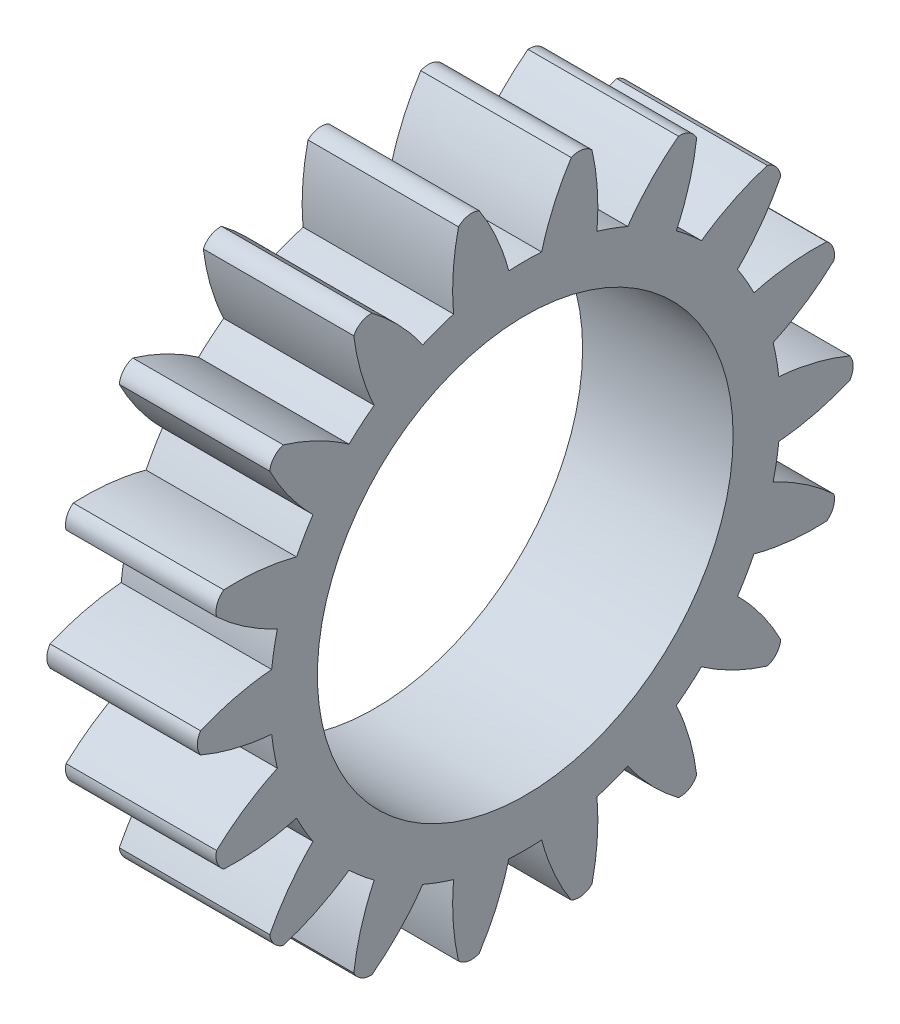
from build123d import *

# Parameters (mm, degrees)
BASPROSKE_W                          = 8
BASPROSKE_H                          = 17.5
TOOTHCUT_DEPTH                       = 27.009613607
TEETHCUTS_COUNT                      = 18
TEETHCUTS_ANGLE                      = 340
BORSKE_R                             = 4
BORE_DEPTH                           = 50.0000508
ESQUISSE1_R                          = 11.05
ENL_V_MAT_EXTRU_1_DEPTH              = 10
ENL_V_MAT_EXTRU_2_DEPTH              = 10
R_P_TITION_CIRCULAIRE1_COUNT         = 18
R_P_TITION_CIRCULAIRE1_COPY_1_DEPTH  = 10
R_P_TITION_CIRCULAIRE1_COPY_2_DEPTH  = 10
R_P_TITION_CIRCULAIRE1_COPY_3_DEPTH  = 10
R_P_TITION_CIRCULAIRE1_COPY_4_DEPTH  = 10
R_P_TITION_CIRCULAIRE1_COPY_5_DEPTH  = 10
R_P_TITION_CIRCULAIRE1_COPY_6_DEPTH  = 10
R_P_TITION_CIRCULAIRE1_COPY_7_DEPTH  = 10
R_P_TITION_CIRCULAIRE1_COPY_8_DEPTH  = 10
R_P_TITION_CIRCULAIRE1_COPY_9_DEPTH  = 10
R_P_TITION_CIRCULAIRE1_COPY_10_DEPTH = 10
R_P_TITION_CIRCULAIRE1_COPY_11_DEPTH = 10
R_P_TITION_CIRCULAIRE1_COPY_12_DEPTH = 10
R_P_TITION_CIRCULAIRE1_COPY_13_DEPTH = 10
R_P_TITION_CIRCULAIRE1_COPY_14_DEPTH = 10
R_P_TITION_CIRCULAIRE1_COPY_15_DEPTH = 10
R_P_TITION_CIRCULAIRE1_COPY_16_DEPTH = 10
R_P_TITION_CIRCULAIRE1_COPY_17_DEPTH = 10


with BuildPart() as part:
    # BasProSke → Base-Revolve (revolve)
    with BuildSketch(Plane(origin=(0, 0, 0), x_dir=(1, 0, 0), z_dir=(0, 1, 0)), mode=Mode.PRIVATE) as base_revolve_sk:
        with Locations((4, 8.75)):
            Rectangle(BASPROSKE_W, BASPROSKE_H)
    revolve(base_revolve_sk.sketch.rotate(Axis((-10, 0, 0), (1, 0, 0)), 180), axis=Axis((-10, 0, 0), (1, 0, 0)))

    # TooCutSke → ToothCut (cut, through all)
    with BuildSketch(Plane(origin=(0, 0, 0), x_dir=(0, 0, -1), z_dir=(1, 0, 0))):
        with BuildLine():
            ThreePointArc((0.873326889, 13.533350745), (0, 13.5615), (-0.873326889, 13.533350745))
            ThreePointArc((-0.873326889, 13.533350745), (-1.417662776, 15.579682129), (-2.609262071, 17.330072031))
            ThreePointArc((-2.609262071, 17.330072031), (0, 17.5254), (2.609262071, 17.330072031))
            ThreePointArc((2.609262071, 17.330072031), (1.417662776, 15.579682129), (0.873326889, 13.533350745))
        make_face()
    toothcut = extrude(amount=TOOTHCUT_DEPTH, mode=Mode.SUBTRACT)

    # TeethCuts: ToothCut ×18 about axis
    teethcuts_axis = Axis((-10, 0, 0), (1, 0, 0))
    for i in range(1, TEETHCUTS_COUNT):
        add(toothcut.rotate(teethcuts_axis, i * TEETHCUTS_ANGLE / (TEETHCUTS_COUNT - 1)), mode=Mode.SUBTRACT)

    # BorSke → Bore (cut, symmetric)
    with BuildSketch(Plane(origin=(0, 0, 0), x_dir=(0, 0, -1), z_dir=(1, 0, 0))):
        with Locations(Location((0, 0, 0), (0, 0, 180))):
            Circle(BORSKE_R)
    extrude(amount=BORE_DEPTH, both=True, mode=Mode.SUBTRACT)

    # Esquisse1 → Enlèv. mat.-Extru.1 (cut)
    with BuildSketch(Plane(origin=(8, 0, 0), x_dir=(0, 0, -1), z_dir=(1, 0, 0))):
        Circle(ESQUISSE1_R)
    extrude(amount=-ENL_V_MAT_EXTRU_1_DEPTH, mode=Mode.SUBTRACT)

    # Esquisse3 → Enlèv. mat.-Extru.2 (cut)
    with BuildSketch(Plane(origin=(8, 0, 0), x_dir=(0, 0, -1), z_dir=(1, 0, 0))):
        with BuildLine():
            add(Edge.make_bspline(
                [(13.479400361, 1.489982603), (15.446382993, 1.323934244), (17.259242087, 0.558889578)],
                knots=[0.341918243, 0.341918243, 0.341918243, 1.280941838, 1.280941838, 1.280941838], degree=2))
            ThreePointArc((17.259242087, 0.558889578), (17.386358219, 0.292196777), (17.43, 0))
            Line((17.43, 0), (17.5, 0))
            ThreePointArc((17.5, 0), (17.498507864, 0.228522471), (17.494031712, 0.457005973))
            ThreePointArc((17.494031712, 0.457005973), (15.574110911, 1.313151733), (13.479400361, 1.489982603))
        make_face()
    enl_v_mat_extru_2 = extrude(amount=-ENL_V_MAT_EXTRU_2_DEPTH, mode=Mode.SUBTRACT)

    # Symétrie1: Enlèv. mat.-Extru.2 across plane
    add(enl_v_mat_extru_2.mirror(Plane.ZX), mode=Mode.SUBTRACT)

    # Répétition circulaire1: Enlèv. mat.-Extru.2 ×18 about axis
    r_p_tition_circulaire1_axis = Axis((-2, 0, 0), (1, 0, 0))
    for i in range(1, R_P_TITION_CIRCULAIRE1_COUNT):
        add(enl_v_mat_extru_2.rotate(r_p_tition_circulaire1_axis, i * 360 / R_P_TITION_CIRCULAIRE1_COUNT), mode=Mode.SUBTRACT)

    # Répétition circulaire1 copy 1 sketch → Répétition circulaire1 copy 1 (cut)
    with BuildSketch(Plane(origin=(8, 0, 0), x_dir=(0, 0.3420201433256687, -0.9396926207859084), z_dir=(1, 0, 0))):
        with BuildLine():
            add(Edge.make_bspline(
                [(13.479400361, -1.489982603), (15.446382993, -1.323934244), (17.259242087, -0.558889578)],
                knots=[0.341918243, 0.341918243, 0.341918243, 1.280941838, 1.280941838, 1.280941838], degree=2))
            ThreePointArc((17.259242087, -0.558889578), (17.386358219, -0.292196777), (17.43, 0))
            Line((17.43, 0), (17.5, 0))
            ThreePointArc((17.5, 0), (17.498507864, -0.228522471), (17.494031712, -0.457005973))
            ThreePointArc((17.494031712, -0.457005973), (15.574110911, -1.313151733), (13.479400361, -1.489982603))
        make_face()
    extrude(amount=-R_P_TITION_CIRCULAIRE1_COPY_1_DEPTH, mode=Mode.SUBTRACT)

    # Répétition circulaire1 copy 2 sketch → Répétition circulaire1 copy 2 (cut)
    with BuildSketch(Plane(origin=(8, 0, 0), x_dir=(0, 0.6427876096865393, -0.766044443118978), z_dir=(1, 0, 0))):
        with BuildLine():
            add(Edge.make_bspline(
                [(13.479400361, -1.489982603), (15.446382993, -1.323934244), (17.259242087, -0.558889578)],
                knots=[0.341918243, 0.341918243, 0.341918243, 1.280941838, 1.280941838, 1.280941838], degree=2))
            ThreePointArc((17.259242087, -0.558889578), (17.386358219, -0.292196777), (17.43, 0))
            Line((17.43, 0), (17.5, 0))
            ThreePointArc((17.5, 0), (17.498507864, -0.228522471), (17.494031712, -0.457005973))
            ThreePointArc((17.494031712, -0.457005973), (15.574110911, -1.313151733), (13.479400361, -1.489982603))
        make_face()
    extrude(amount=-R_P_TITION_CIRCULAIRE1_COPY_2_DEPTH, mode=Mode.SUBTRACT)

    # Répétition circulaire1 copy 3 sketch → Répétition circulaire1 copy 3 (cut)
    with BuildSketch(Plane(origin=(8, 0, 0), x_dir=(0, 0.8660254037844386, -0.5000000000000001), z_dir=(1, 0, 0))):
        with BuildLine():
            add(Edge.make_bspline(
                [(13.479400361, -1.489982603), (15.446382993, -1.323934244), (17.259242087, -0.558889578)],
                knots=[0.341918243, 0.341918243, 0.341918243, 1.280941838, 1.280941838, 1.280941838], degree=2))
            ThreePointArc((17.259242087, -0.558889578), (17.386358219, -0.292196777), (17.43, 0))
            Line((17.43, 0), (17.5, 0))
            ThreePointArc((17.5, 0), (17.498507864, -0.228522471), (17.494031712, -0.457005973))
            ThreePointArc((17.494031712, -0.457005973), (15.574110911, -1.313151733), (13.479400361, -1.489982603))
        make_face()
    extrude(amount=-R_P_TITION_CIRCULAIRE1_COPY_3_DEPTH, mode=Mode.SUBTRACT)

    # Répétition circulaire1 copy 4 sketch → Répétition circulaire1 copy 4 (cut)
    with BuildSketch(Plane(origin=(8, 0, 0), x_dir=(0, 0.984807753012208, -0.17364817766693041), z_dir=(1, 0, 0))):
        with BuildLine():
            add(Edge.make_bspline(
                [(13.479400361, -1.489982603), (15.446382993, -1.323934244), (17.259242087, -0.558889578)],
                knots=[0.341918243, 0.341918243, 0.341918243, 1.280941838, 1.280941838, 1.280941838], degree=2))
            ThreePointArc((17.259242087, -0.558889578), (17.386358219, -0.292196777), (17.43, 0))
            Line((17.43, 0), (17.5, 0))
            ThreePointArc((17.5, 0), (17.498507864, -0.228522471), (17.494031712, -0.457005973))
            ThreePointArc((17.494031712, -0.457005973), (15.574110911, -1.313151733), (13.479400361, -1.489982603))
        make_face()
    extrude(amount=-R_P_TITION_CIRCULAIRE1_COPY_4_DEPTH, mode=Mode.SUBTRACT)

    # Répétition circulaire1 copy 5 sketch → Répétition circulaire1 copy 5 (cut)
    with BuildSketch(Plane(origin=(8, 0, 0), x_dir=(0, 0.984807753012208, 0.1736481776669303), z_dir=(1, 0, 0))):
        with BuildLine():
            add(Edge.make_bspline(
                [(13.479400361, -1.489982603), (15.446382993, -1.323934244), (17.259242087, -0.558889578)],
                knots=[0.341918243, 0.341918243, 0.341918243, 1.280941838, 1.280941838, 1.280941838], degree=2))
            ThreePointArc((17.259242087, -0.558889578), (17.386358219, -0.292196777), (17.43, 0))
            Line((17.43, 0), (17.5, 0))
            ThreePointArc((17.5, 0), (17.498507864, -0.228522471), (17.494031712, -0.457005973))
            ThreePointArc((17.494031712, -0.457005973), (15.574110911, -1.313151733), (13.479400361, -1.489982603))
        make_face()
    extrude(amount=-R_P_TITION_CIRCULAIRE1_COPY_5_DEPTH, mode=Mode.SUBTRACT)

    # Répétition circulaire1 copy 6 sketch → Répétition circulaire1 copy 6 (cut)
    with BuildSketch(Plane(origin=(8, 0, 0), x_dir=(0, 0.8660254037844387, 0.4999999999999998), z_dir=(1, 0, 0))):
        with BuildLine():
            add(Edge.make_bspline(
                [(13.479400361, -1.489982603), (15.446382993, -1.323934244), (17.259242087, -0.558889578)],
                knots=[0.341918243, 0.341918243, 0.341918243, 1.280941838, 1.280941838, 1.280941838], degree=2))
            ThreePointArc((17.259242087, -0.558889578), (17.386358219, -0.292196777), (17.43, 0))
            Line((17.43, 0), (17.5, 0))
            ThreePointArc((17.5, 0), (17.498507864, -0.228522471), (17.494031712, -0.457005973))
            ThreePointArc((17.494031712, -0.457005973), (15.574110911, -1.313151733), (13.479400361, -1.489982603))
        make_face()
    extrude(amount=-R_P_TITION_CIRCULAIRE1_COPY_6_DEPTH, mode=Mode.SUBTRACT)

    # Répétition circulaire1 copy 7 sketch → Répétition circulaire1 copy 7 (cut)
    with BuildSketch(Plane(origin=(8, 0, 0), x_dir=(0, 0.6427876096865395, 0.7660444431189779), z_dir=(1, 0, 0))):
        with BuildLine():
            add(Edge.make_bspline(
                [(13.479400361, -1.489982603), (15.446382993, -1.323934244), (17.259242087, -0.558889578)],
                knots=[0.341918243, 0.341918243, 0.341918243, 1.280941838, 1.280941838, 1.280941838], degree=2))
            ThreePointArc((17.259242087, -0.558889578), (17.386358219, -0.292196777), (17.43, 0))
            Line((17.43, 0), (17.5, 0))
            ThreePointArc((17.5, 0), (17.498507864, -0.228522471), (17.494031712, -0.457005973))
            ThreePointArc((17.494031712, -0.457005973), (15.574110911, -1.313151733), (13.479400361, -1.489982603))
        make_face()
    extrude(amount=-R_P_TITION_CIRCULAIRE1_COPY_7_DEPTH, mode=Mode.SUBTRACT)

    # Répétition circulaire1 copy 8 sketch → Répétition circulaire1 copy 8 (cut)
    with BuildSketch(Plane(origin=(8, 0, 0), x_dir=(0, 0.3420201433256689, 0.9396926207859083), z_dir=(1, 0, 0))):
        with BuildLine():
            add(Edge.make_bspline(
                [(13.479400361, -1.489982603), (15.446382993, -1.323934244), (17.259242087, -0.558889578)],
                knots=[0.341918243, 0.341918243, 0.341918243, 1.280941838, 1.280941838, 1.280941838], degree=2))
            ThreePointArc((17.259242087, -0.558889578), (17.386358219, -0.292196777), (17.43, 0))
            Line((17.43, 0), (17.5, 0))
            ThreePointArc((17.5, 0), (17.498507864, -0.228522471), (17.494031712, -0.457005973))
            ThreePointArc((17.494031712, -0.457005973), (15.574110911, -1.313151733), (13.479400361, -1.489982603))
        make_face()
    extrude(amount=-R_P_TITION_CIRCULAIRE1_COPY_8_DEPTH, mode=Mode.SUBTRACT)

    # Répétition circulaire1 copy 9 sketch → Répétition circulaire1 copy 9 (cut)
    with BuildSketch(Plane(origin=(8, 0, 0), x_dir=(0, 0, 1), z_dir=(1, 0, 0))):
        with BuildLine():
            add(Edge.make_bspline(
                [(13.479400361, -1.489982603), (15.446382993, -1.323934244), (17.259242087, -0.558889578)],
                knots=[0.341918243, 0.341918243, 0.341918243, 1.280941838, 1.280941838, 1.280941838], degree=2))
            ThreePointArc((17.259242087, -0.558889578), (17.386358219, -0.292196777), (17.43, 0))
            Line((17.43, 0), (17.5, 0))
            ThreePointArc((17.5, 0), (17.498507864, -0.228522471), (17.494031712, -0.457005973))
            ThreePointArc((17.494031712, -0.457005973), (15.574110911, -1.313151733), (13.479400361, -1.489982603))
        make_face()
    extrude(amount=-R_P_TITION_CIRCULAIRE1_COPY_9_DEPTH, mode=Mode.SUBTRACT)

    # Répétition circulaire1 copy 10 sketch → Répétition circulaire1 copy 10 (cut)
    with BuildSketch(Plane(origin=(8, 0, 0), x_dir=(0, -0.34202014332566866, 0.9396926207859084), z_dir=(1, 0, 0))):
        with BuildLine():
            add(Edge.make_bspline(
                [(13.479400361, -1.489982603), (15.446382993, -1.323934244), (17.259242087, -0.558889578)],
                knots=[0.341918243, 0.341918243, 0.341918243, 1.280941838, 1.280941838, 1.280941838], degree=2))
            ThreePointArc((17.259242087, -0.558889578), (17.386358219, -0.292196777), (17.43, 0))
            Line((17.43, 0), (17.5, 0))
            ThreePointArc((17.5, 0), (17.498507864, -0.228522471), (17.494031712, -0.457005973))
            ThreePointArc((17.494031712, -0.457005973), (15.574110911, -1.313151733), (13.479400361, -1.489982603))
        make_face()
    extrude(amount=-R_P_TITION_CIRCULAIRE1_COPY_10_DEPTH, mode=Mode.SUBTRACT)

    # Répétition circulaire1 copy 11 sketch → Répétition circulaire1 copy 11 (cut)
    with BuildSketch(Plane(origin=(8, 0, 0), x_dir=(0, -0.6427876096865393, 0.766044443118978), z_dir=(1, 0, 0))):
        with BuildLine():
            add(Edge.make_bspline(
                [(13.479400361, -1.489982603), (15.446382993, -1.323934244), (17.259242087, -0.558889578)],
                knots=[0.341918243, 0.341918243, 0.341918243, 1.280941838, 1.280941838, 1.280941838], degree=2))
            ThreePointArc((17.259242087, -0.558889578), (17.386358219, -0.292196777), (17.43, 0))
            Line((17.43, 0), (17.5, 0))
            ThreePointArc((17.5, 0), (17.498507864, -0.228522471), (17.494031712, -0.457005973))
            ThreePointArc((17.494031712, -0.457005973), (15.574110911, -1.313151733), (13.479400361, -1.489982603))
        make_face()
    extrude(amount=-R_P_TITION_CIRCULAIRE1_COPY_11_DEPTH, mode=Mode.SUBTRACT)

    # Répétition circulaire1 copy 12 sketch → Répétition circulaire1 copy 12 (cut)
    with BuildSketch(Plane(origin=(8, 0, 0), x_dir=(0, -0.8660254037844384, 0.5000000000000004), z_dir=(1, 0, 0))):
        with BuildLine():
            add(Edge.make_bspline(
                [(13.479400361, -1.489982603), (15.446382993, -1.323934244), (17.259242087, -0.558889578)],
                knots=[0.341918243, 0.341918243, 0.341918243, 1.280941838, 1.280941838, 1.280941838], degree=2))
            ThreePointArc((17.259242087, -0.558889578), (17.386358219, -0.292196777), (17.43, 0))
            Line((17.43, 0), (17.5, 0))
            ThreePointArc((17.5, 0), (17.498507864, -0.228522471), (17.494031712, -0.457005973))
            ThreePointArc((17.494031712, -0.457005973), (15.574110911, -1.313151733), (13.479400361, -1.489982603))
        make_face()
    extrude(amount=-R_P_TITION_CIRCULAIRE1_COPY_12_DEPTH, mode=Mode.SUBTRACT)

    # Répétition circulaire1 copy 13 sketch → Répétition circulaire1 copy 13 (cut)
    with BuildSketch(Plane(origin=(8, 0, 0), x_dir=(0, -0.984807753012208, 0.17364817766693033), z_dir=(1, 0, 0))):
        with BuildLine():
            add(Edge.make_bspline(
                [(13.479400361, -1.489982603), (15.446382993, -1.323934244), (17.259242087, -0.558889578)],
                knots=[0.341918243, 0.341918243, 0.341918243, 1.280941838, 1.280941838, 1.280941838], degree=2))
            ThreePointArc((17.259242087, -0.558889578), (17.386358219, -0.292196777), (17.43, 0))
            Line((17.43, 0), (17.5, 0))
            ThreePointArc((17.5, 0), (17.498507864, -0.228522471), (17.494031712, -0.457005973))
            ThreePointArc((17.494031712, -0.457005973), (15.574110911, -1.313151733), (13.479400361, -1.489982603))
        make_face()
    extrude(amount=-R_P_TITION_CIRCULAIRE1_COPY_13_DEPTH, mode=Mode.SUBTRACT)

    # Répétition circulaire1 copy 14 sketch → Répétition circulaire1 copy 14 (cut)
    with BuildSketch(Plane(origin=(8, 0, 0), x_dir=(0, -0.9848077530122081, -0.17364817766692997), z_dir=(1, 0, 0))):
        with BuildLine():
            add(Edge.make_bspline(
                [(13.479400361, -1.489982603), (15.446382993, -1.323934244), (17.259242087, -0.558889578)],
                knots=[0.341918243, 0.341918243, 0.341918243, 1.280941838, 1.280941838, 1.280941838], degree=2))
            ThreePointArc((17.259242087, -0.558889578), (17.386358219, -0.292196777), (17.43, 0))
            Line((17.43, 0), (17.5, 0))
            ThreePointArc((17.5, 0), (17.498507864, -0.228522471), (17.494031712, -0.457005973))
            ThreePointArc((17.494031712, -0.457005973), (15.574110911, -1.313151733), (13.479400361, -1.489982603))
        make_face()
    extrude(amount=-R_P_TITION_CIRCULAIRE1_COPY_14_DEPTH, mode=Mode.SUBTRACT)

    # Répétition circulaire1 copy 15 sketch → Répétition circulaire1 copy 15 (cut)
    with BuildSketch(Plane(origin=(8, 0, 0), x_dir=(0, -0.8660254037844386, -0.5000000000000001), z_dir=(1, 0, 0))):
        with BuildLine():
            add(Edge.make_bspline(
                [(13.479400361, -1.489982603), (15.446382993, -1.323934244), (17.259242087, -0.558889578)],
                knots=[0.341918243, 0.341918243, 0.341918243, 1.280941838, 1.280941838, 1.280941838], degree=2))
            ThreePointArc((17.259242087, -0.558889578), (17.386358219, -0.292196777), (17.43, 0))
            Line((17.43, 0), (17.5, 0))
            ThreePointArc((17.5, 0), (17.498507864, -0.228522471), (17.494031712, -0.457005973))
            ThreePointArc((17.494031712, -0.457005973), (15.574110911, -1.313151733), (13.479400361, -1.489982603))
        make_face()
    extrude(amount=-R_P_TITION_CIRCULAIRE1_COPY_15_DEPTH, mode=Mode.SUBTRACT)

    # Répétition circulaire1 copy 16 sketch → Répétition circulaire1 copy 16 (cut)
    with BuildSketch(Plane(origin=(8, 0, 0), x_dir=(0, -0.6427876096865396, -0.7660444431189778), z_dir=(1, 0, 0))):
        with BuildLine():
            add(Edge.make_bspline(
                [(13.479400361, -1.489982603), (15.446382993, -1.323934244), (17.259242087, -0.558889578)],
                knots=[0.341918243, 0.341918243, 0.341918243, 1.280941838, 1.280941838, 1.280941838], degree=2))
            ThreePointArc((17.259242087, -0.558889578), (17.386358219, -0.292196777), (17.43, 0))
            Line((17.43, 0), (17.5, 0))
            ThreePointArc((17.5, 0), (17.498507864, -0.228522471), (17.494031712, -0.457005973))
            ThreePointArc((17.494031712, -0.457005973), (15.574110911, -1.313151733), (13.479400361, -1.489982603))
        make_face()
    extrude(amount=-R_P_TITION_CIRCULAIRE1_COPY_16_DEPTH, mode=Mode.SUBTRACT)

    # Répétition circulaire1 copy 17 sketch → Répétition circulaire1 copy 17 (cut)
    with BuildSketch(Plane(origin=(8, 0, 0), x_dir=(0, -0.3420201433256686, -0.9396926207859084), z_dir=(1, 0, 0))):
        with BuildLine():
            add(Edge.make_bspline(
                [(13.479400361, -1.489982603), (15.446382993, -1.323934244), (17.259242087, -0.558889578)],
                knots=[0.341918243, 0.341918243, 0.341918243, 1.280941838, 1.280941838, 1.280941838], degree=2))
            ThreePointArc((17.259242087, -0.558889578), (17.386358219, -0.292196777), (17.43, 0))
            Line((17.43, 0), (17.5, 0))
            ThreePointArc((17.5, 0), (17.498507864, -0.228522471), (17.494031712, -0.457005973))
            ThreePointArc((17.494031712, -0.457005973), (15.574110911, -1.313151733), (13.479400361, -1.489982603))
        make_face()
    extrude(amount=-R_P_TITION_CIRCULAIRE1_COPY_17_DEPTH, mode=Mode.SUBTRACT)


solid = part.part
